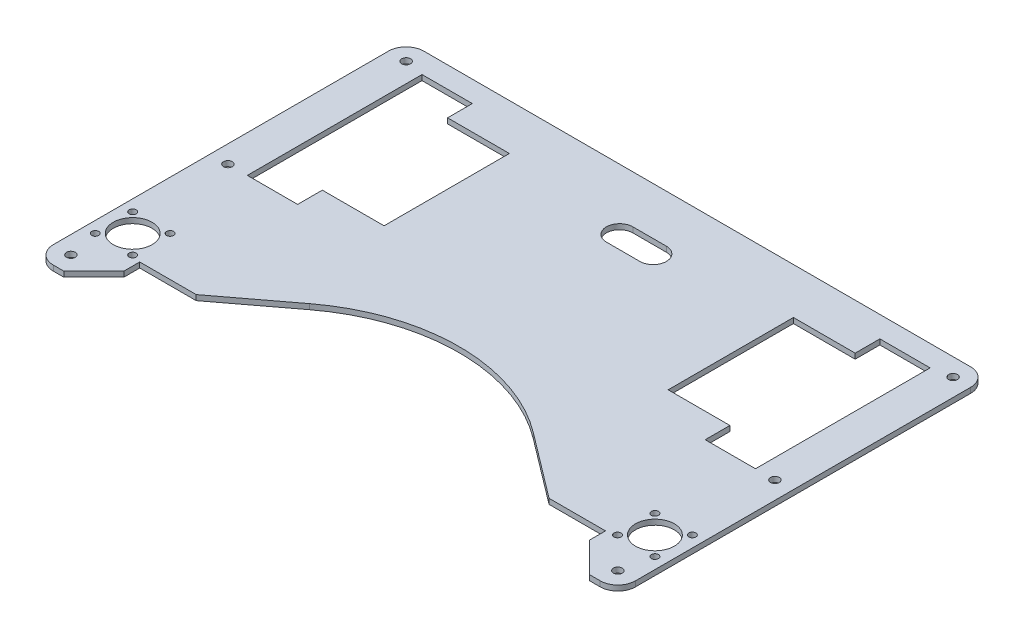
from build123d import *

# Parameters (mm, degrees)
ESQUISSE1_R      = 2.5
ESQUISSE1_R_2    = 11
ESQUISSE1_R_3    = 2
EXTRUSION1_DEPTH = 3
CONG_1_R         = 10


with BuildPart() as part:
    # Esquisse1 → Extrusion1 (new body)
    with BuildSketch(Plane(origin=(0, 0, 0), x_dir=(1, 0, 0), z_dir=(0, 1, 0))):
        with BuildLine():
            Line((165, 0), (-165, 0))
            Line((-165, 0), (-165, -210))
            Line((-165, -210), (-149, -210))
            Line((-149, -210), (-132, -193))
            Line((-132, -193), (-132, -184))
            Line((-132, -184), (-100, -184))
            Line((-100, -184), (-63.363257782, -156.27367461))
            ThreePointArc((-63.363257782, -156.27367461), (0, -135), (63.363257782, -156.27367461))
            Line((63.363257782, -156.27367461), (100, -184))
            Line((100, -184), (132, -184))
            Line((132, -184), (132, -193))
            Line((132, -193), (149, -210))
            Line((149, -210), (165, -210))
            Line((165, -210), (165, 0))
        make_face()
        with Locations((-155, -10)):
            Circle(ESQUISSE1_R, mode=Mode.SUBTRACT)
        with Locations((155, -10)):
            Circle(ESQUISSE1_R, mode=Mode.SUBTRACT)
        with Locations((-155, -200)):
            Circle(ESQUISSE1_R, mode=Mode.SUBTRACT)
        with Locations((155, -200)):
            Circle(ESQUISSE1_R, mode=Mode.SUBTRACT)
        with Locations((-148, -172)):
            Circle(ESQUISSE1_R_2, mode=Mode.SUBTRACT)
        with Locations((-158.606601718, -161.393398282)):
            Circle(ESQUISSE1_R_3, mode=Mode.SUBTRACT)
        with Locations((-137.393398282, -161.393398282)):
            Circle(ESQUISSE1_R_3, mode=Mode.SUBTRACT)
        with Locations((-137.393398282, -182.606601718)):
            Circle(ESQUISSE1_R_3, mode=Mode.SUBTRACT)
        with Locations((-158.606601718, -182.606601718)):
            Circle(ESQUISSE1_R_3, mode=Mode.SUBTRACT)
        with Locations((148, -172)):
            Circle(ESQUISSE1_R_2, mode=Mode.SUBTRACT)
        with Locations((158.606601718, -182.606601718)):
            Circle(ESQUISSE1_R_3, mode=Mode.SUBTRACT)
        with Locations((137.393398282, -182.606601718)):
            Circle(ESQUISSE1_R_3, mode=Mode.SUBTRACT)
        with Locations((137.393398282, -161.393398282)):
            Circle(ESQUISSE1_R_3, mode=Mode.SUBTRACT)
        with Locations((158.606601718, -161.393398282)):
            Circle(ESQUISSE1_R_3, mode=Mode.SUBTRACT)
        with Locations((-155, -111)):
            Circle(ESQUISSE1_R, mode=Mode.SUBTRACT)
        with Locations((155, -111)):
            Circle(ESQUISSE1_R, mode=Mode.SUBTRACT)
        Polygon((-80.5, -26), (-115.5, -26), (-115.5, -12), (-144, -12), (-144, -111), (-115.5, -111), (-115.5, -97), (-80.5, -97), align=None, mode=Mode.SUBTRACT)
        Polygon((115.5, -26), (115.5, -12), (144, -12), (144, -111), (115.5, -111), (115.5, -97), (80.5, -97), (80.5, -26), align=None, mode=Mode.SUBTRACT)
        with BuildLine():
            Line((9.5, -27), (-9.5, -27))
            ThreePointArc((-9.5, -27), (-17, -34.5), (-9.5, -42))
            Line((-9.5, -42), (9.5, -42))
            ThreePointArc((9.5, -42), (17, -34.5), (9.5, -27))
        make_face(mode=Mode.SUBTRACT)
    extrude(amount=EXTRUSION1_DEPTH)

    # Congé1
    cong_1_edges = [part.edges().sort_by_distance(p)[0] for p in [
        (-165, 1.5, 0),
        (165, 1.5, 0),
        (165, 1.5, 210),
        (-165, 1.5, 210),
    ]]
    fillet(cong_1_edges, radius=CONG_1_R)


solid = part.part
